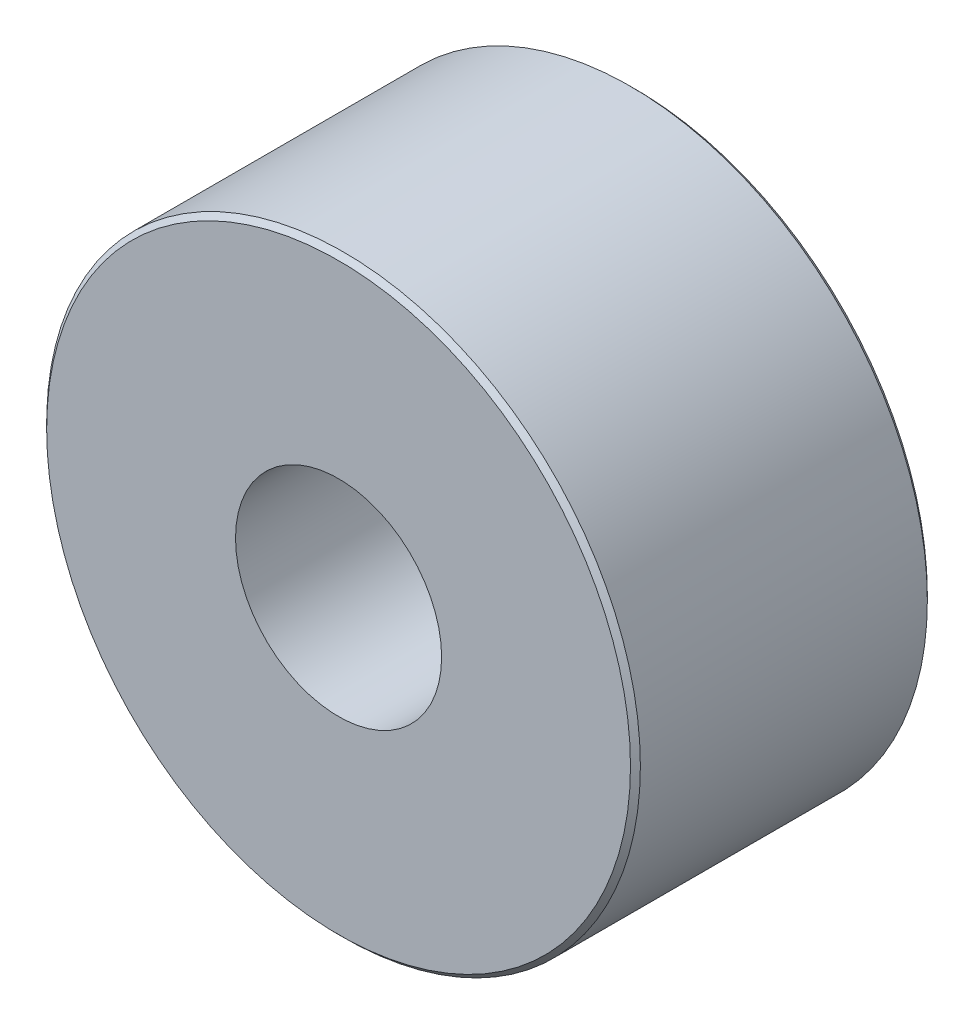
from build123d import *

# Parameters (mm, degrees)
SKETCH1_R                       = 6
BOSS_EXTRUDE1_DEPTH             = 6
F_8_32_TAPPED_HOLE1_D           = 3.4544
F_8_32_TAPPED_HOLE1_DEPTH       = 5.1
F_8_32_TAPPED_HOLE1_CBORE_D     = 4.1656
F_8_32_TAPPED_HOLE1_CBORE_DEPTH = 4.2
F_8_32_TAPPED_HOLE1_TIP         = 1.037806461
CHAMFER1_SIZE                   = 0.1


with BuildPart() as part:
    # Sketch1 → Boss-Extrude1 (new body)
    with BuildSketch(Plane.XY):
        Circle(SKETCH1_R)
    extrude(amount=BOSS_EXTRUDE1_DEPTH)

    # #8-32 Tapped Hole1
    with Locations(Plane.XY.offset(6)):
        with Locations((0, 0)):
            CounterBoreHole(F_8_32_TAPPED_HOLE1_D / 2, F_8_32_TAPPED_HOLE1_CBORE_D / 2, F_8_32_TAPPED_HOLE1_CBORE_DEPTH, depth=F_8_32_TAPPED_HOLE1_DEPTH)
            with Locations((0, 0, -(F_8_32_TAPPED_HOLE1_DEPTH + F_8_32_TAPPED_HOLE1_TIP / 2))):  # 118° drill point
                Cone(0, F_8_32_TAPPED_HOLE1_D / 2, F_8_32_TAPPED_HOLE1_TIP, mode=Mode.SUBTRACT)

    # Chamfer1
    chamfer1_edges = [part.edges().sort_by_distance(p)[0] for p in [
        (-6, 0, 0),
        (-6, 0, 6),
    ]]
    chamfer(chamfer1_edges, length=CHAMFER1_SIZE)


solid = part.part
